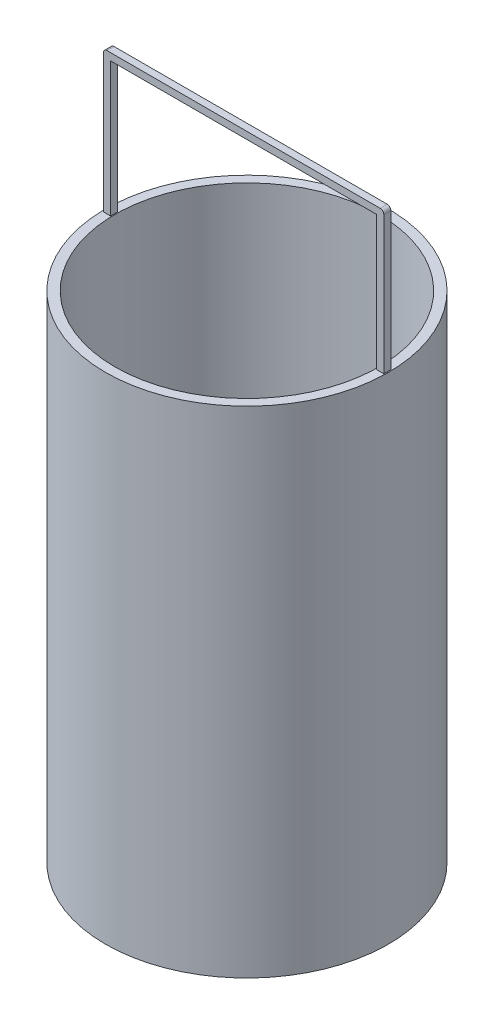
from build123d import *

# Parameters (mm, degrees)
RESSALTO_EXTRUS_O1_DEPTH      = 200
RESSALTO_EXTRUS_O1_DEPTH_BACK = 220
ESBO_O1_R                     = 120
CORTE_EXTRUS_O1_REACH         = 454.99
ESBO_O2_R                     = 112
RESSALTO_EXTRUS_O3_DEPTH      = 3
RESSALTO_EXTRUS_O3_DEPTH_BACK = 3
FILETE2_R                     = 3


with BuildPart() as part:
    # Esboço1 → Ressalto-extrusão1 (new, two sides: drawn at the far end of the back side and taken through both)
    with BuildSketch(Plane(origin=(0, 0, 0), x_dir=(1, 0, 0), z_dir=(0, 1, 0)).offset(-RESSALTO_EXTRUS_O1_DEPTH_BACK)):
        Circle(ESBO_O1_R)
    extrude(amount=RESSALTO_EXTRUS_O1_DEPTH + RESSALTO_EXTRUS_O1_DEPTH_BACK)

    # Esboço2 → Corte-extrusão1 (cut, up to next)
    with BuildSketch(Plane(origin=(0, 200, 0), x_dir=(1, 0, 0), z_dir=(0, 1, 0)), mode=Mode.PRIVATE) as corte_extrus_o1_sk1:
        Circle(ESBO_O2_R)
    corte_extrus_o1_tool1 = extrude(corte_extrus_o1_sk1.sketch, amount=-CORTE_EXTRUS_O1_REACH, mode=Mode.PRIVATE) & part.part
    add(corte_extrus_o1_tool1.solids().sort_by_distance((0, 200, 0))[0], mode=Mode.SUBTRACT)

    # Esboço4 → Ressalto-extrusão3 (add, two sides: drawn at the far end of the back side and taken through both)
    with BuildSketch(Plane.XY.offset(-RESSALTO_EXTRUS_O3_DEPTH_BACK)):
        Polygon((-118.712281772, 320), (-118.712281772, 200), (-112.712281772, 200), (-112.712281772, 314), (113.045365563, 314), (113.045365563, 200), (119.045365563, 200), (119.045365563, 320), align=None)
    extrude(amount=RESSALTO_EXTRUS_O3_DEPTH + RESSALTO_EXTRUS_O3_DEPTH_BACK)

    # Filete2
    filete2_edges = [part.edges().sort_by_distance(p)[0] for p in [
        (-118.712281772, 320, 0),
        (119.045365563, 320, 0),
    ]]
    fillet(filete2_edges, radius=FILETE2_R)


solid = part.part
